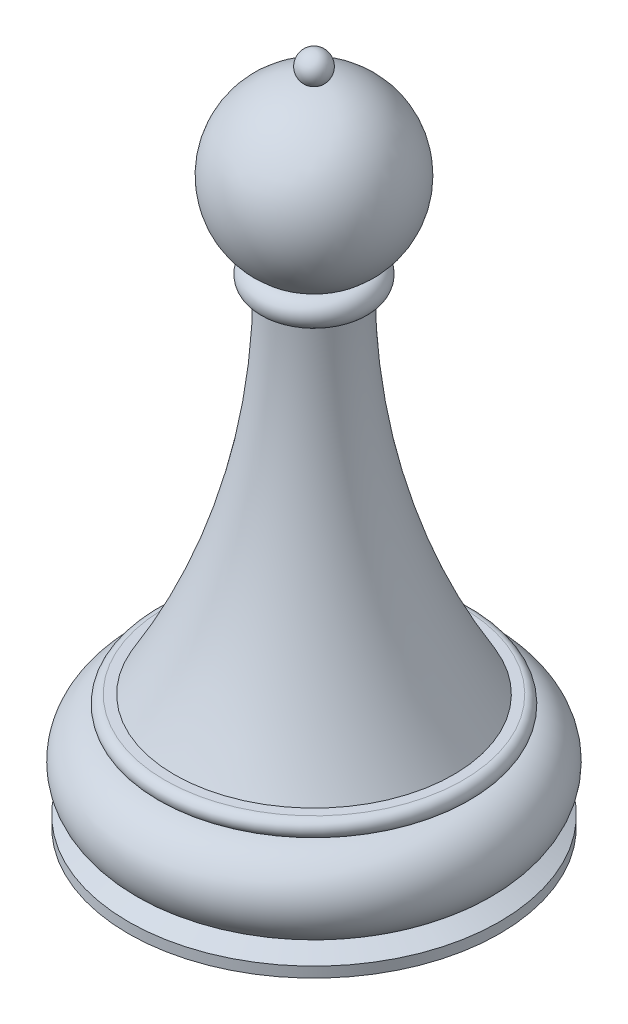
from build123d import *


with BuildPart() as part:
    # Sketch1 → Revolve1 (revolve)
    with BuildSketch(Plane.XY):
        with BuildLine():
            Line((0, 44.385781447), (0, 0))
            Line((0, 0), (11.705326418, 0))
            ThreePointArc((11.705326418, 0), (5.689352, 14.133820258), (3.635037225, 29.356717947))
            Line((3.635037225, 29.356717947), (3.136102118, 29.356717947))
            Line((3.136102118, 29.356717947), (3.136102118, 29.502954512))
            ThreePointArc((3.136102118, 29.502954512), (4.724019261, 30.258758943), (3.629631831, 31.635362497))
            ThreePointArc((3.629631831, 31.635362497), (6.89832899, 39.175563266), (0.811766414, 44.697588688))
            ThreePointArc((0.811766414, 44.697588688), (0.434795488, 44.466414144), (0, 44.385781447))
        make_face()
        with BuildLine():
            Line((15.56268383, -8.751500195), (13.893883706, -7.960560004))
            ThreePointArc((13.893883706, -7.960560004), (15.773602868, -4.136267719), (12.478125528, -1.43471544))
            Line((12.478125528, -1.43471544), (12.478125528, -1.42836544))
            ThreePointArc((12.478125528, -1.42836544), (13.215841354, -0.726095063), (12.5015625, 0))
            Line((12.5015625, 0), (0, 0))
            Line((0, 0), (0, -9.621899232))
            Line((0, -9.621899232), (15.56268383, -9.621899232))
            Line((15.56268383, -9.621899232), (15.56268383, -8.751500195))
        make_face()
        with BuildLine():
            Line((0, 46.810960747), (0, 44.744432756))
            ThreePointArc((0, 44.744432756), (0.406558445, 44.732712005), (0.811766414, 44.697588688))
            ThreePointArc((0.811766414, 44.697588688), (1.131956953, 46.033166585), (0, 46.810960747))
        make_face()
    revolve(axis=Axis((0, 0, 0), (0, -1, 0)))


solid = part.part
